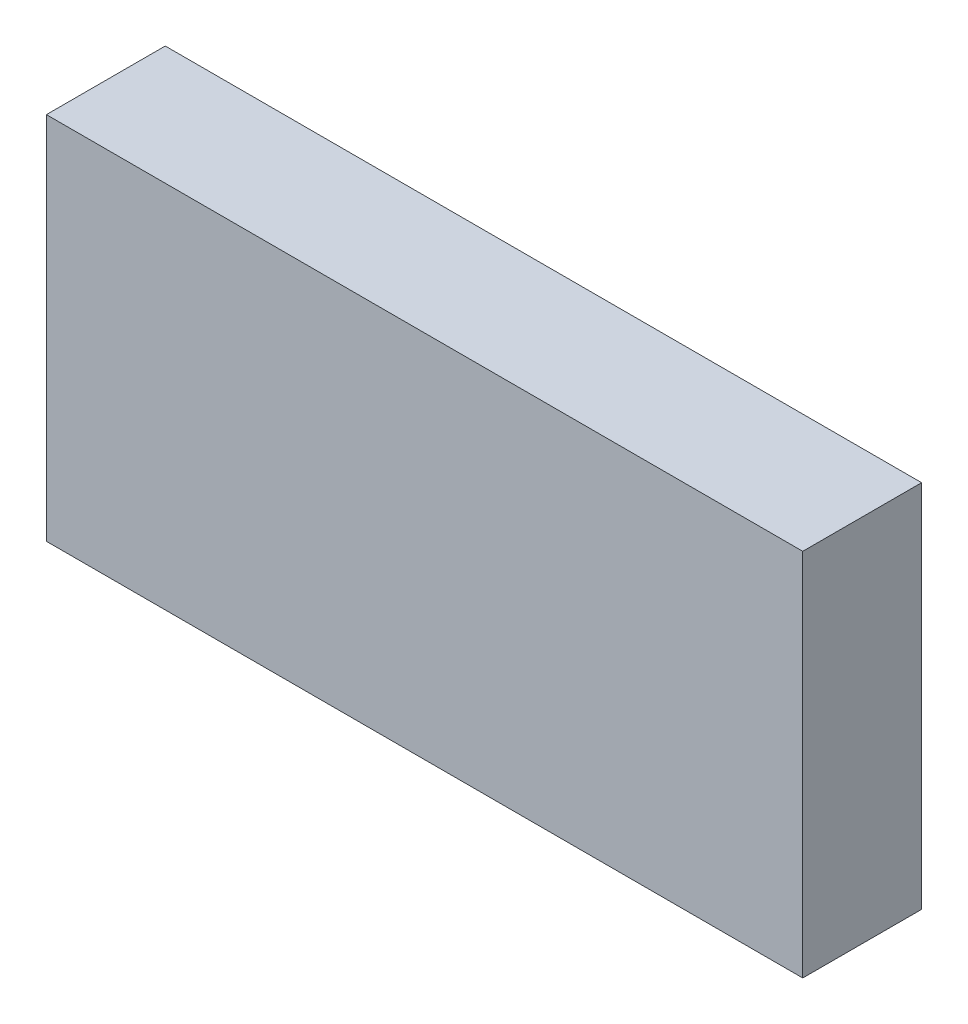
from build123d import *

# Parameters (mm, degrees)
SKETCH1_W           = 35
SKETCH1_H           = 17.1
BOSS_EXTRUDE1_DEPTH = 5.5


with BuildPart() as part:
    # Sketch1 → Boss-Extrude1 (new body)
    with BuildSketch(Plane.XY):
        Rectangle(SKETCH1_W, SKETCH1_H)
    extrude(amount=BOSS_EXTRUDE1_DEPTH)


solid = part.part
